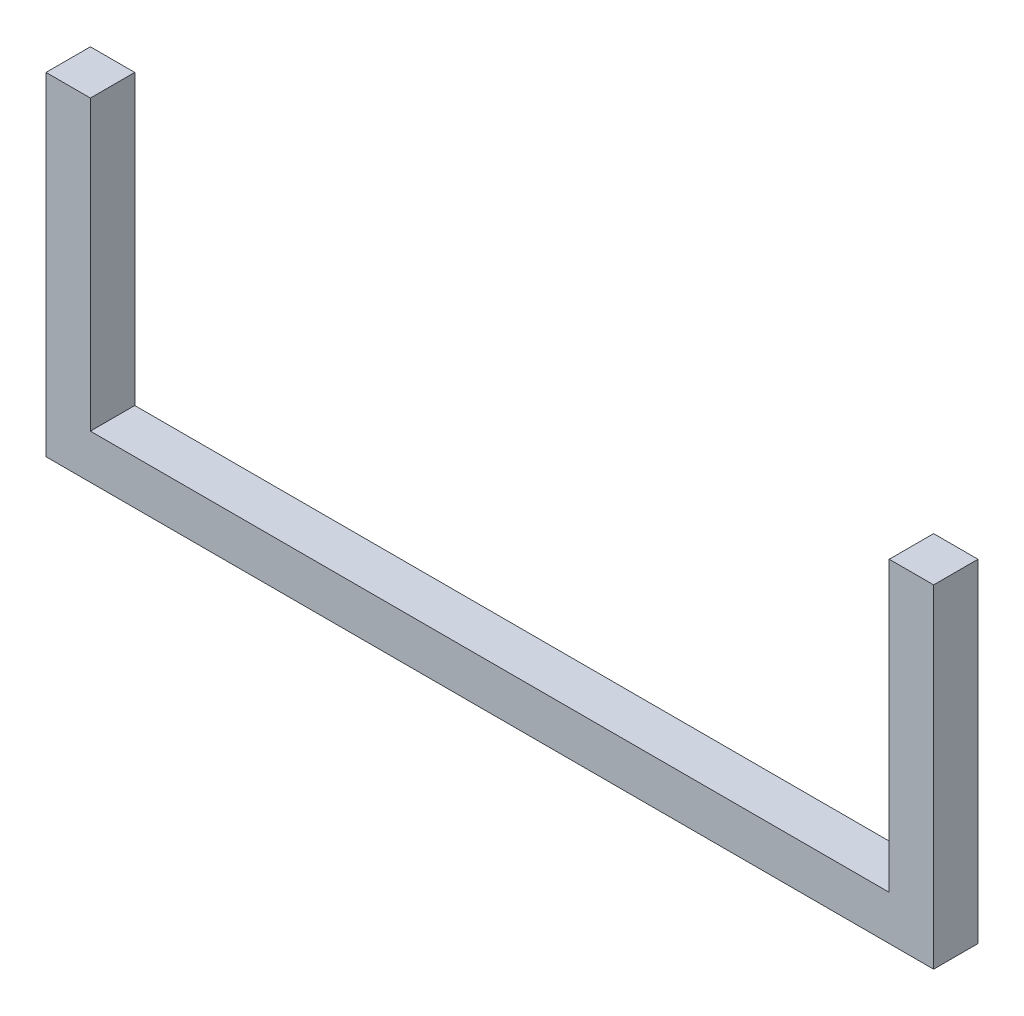
from build123d import *

# Parameters (mm, degrees)
EXTRUDE_1_DEPTH = 20


with BuildPart() as part:
    # 스케치2 → 보스-돌출1 (new body)
    with BuildSketch(Plane.XY):
        Polygon((0, 0), (-400, 0), (-400, 150), (-380, 150), (-380, 20), (-20, 20), (-20, 150), (0, 150), align=None)
    extrude(amount=EXTRUDE_1_DEPTH)


solid = part.part
